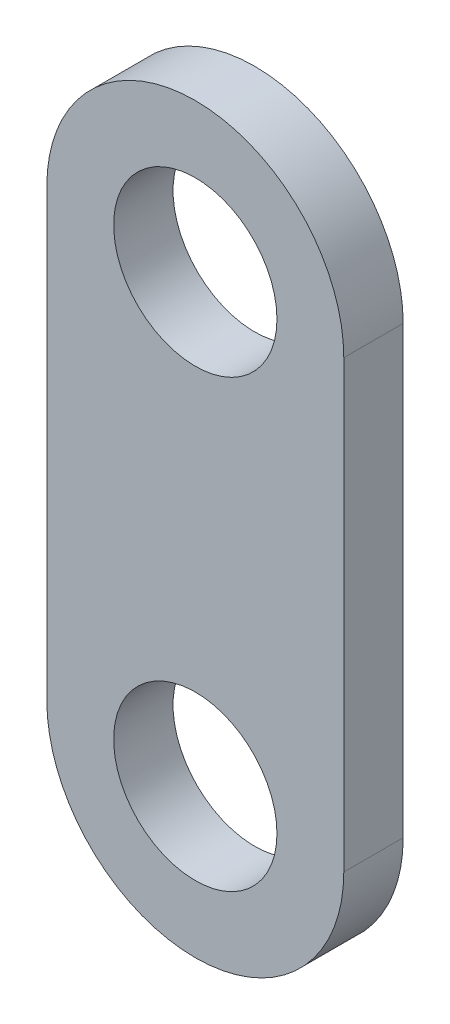
from build123d import *

# Parameters (mm, degrees)
BOSS_EXTRUDE1_DEPTH  = 2
M5_CLEARANCE_HOLE1_D = 5.5


with BuildPart() as part:
    # Sketch1 → Boss-Extrude1 (new body)
    with BuildSketch(Plane.XY):
        with BuildLine():
            Line((5, 7.5), (5, -7.5))
            ThreePointArc((5, -7.5), (0, -12.5), (-5, -7.5))
            Line((-5, -7.5), (-5, 7.5))
            ThreePointArc((-5, 7.5), (0, 12.5), (5, 7.5))
        make_face()
    extrude(amount=BOSS_EXTRUDE1_DEPTH)

    # M5 Clearance Hole1 (through all)
    with Locations(Plane.XY.offset(2)):
        with Locations((0, 7.5), (0, -7.5)):
            Hole(M5_CLEARANCE_HOLE1_D / 2)


solid = part.part
